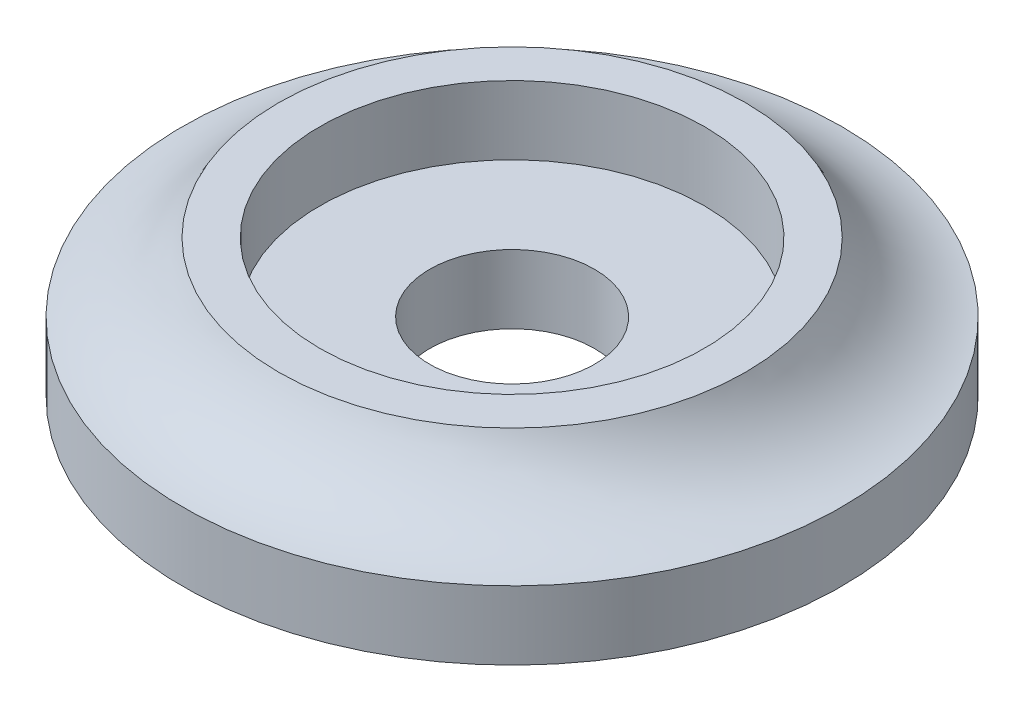
from build123d import *


with BuildPart() as part:
    # Sketch2 → Revolve1 (revolve)
    with BuildSketch(Plane(origin=(0, 0, 0), x_dir=(0, 0, -1), z_dir=(1, 0, 0))):
        with BuildLine():
            Line((12, 0), (12, 2.5))
            ThreePointArc((12, 2.5), (9.932956508, 3.306139112), (8.5, 5))
            Line((8.5, 5), (7, 5))
            Line((7, 5), (7, 2.5))
            Line((7, 2.5), (3, 2.5))
            Line((3, 2.5), (3, 0))
            Line((3, 0), (12, 0))
        make_face()
    revolve(axis=Axis((0, 0, 0), (0, 1, 0)))


solid = part.part
